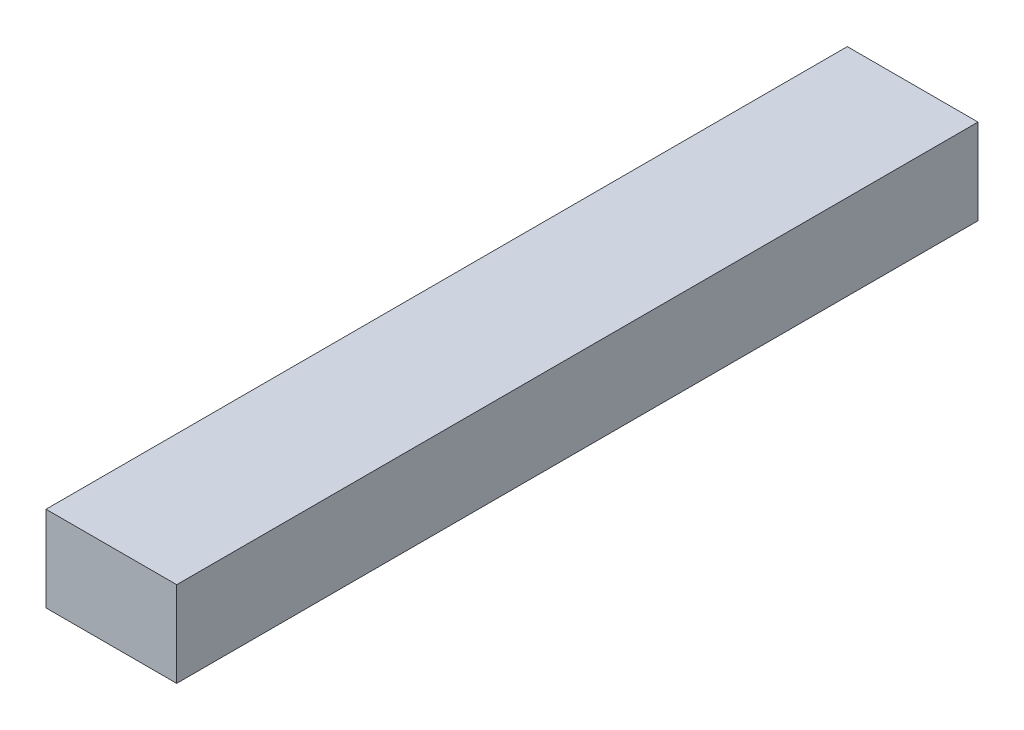
from build123d import *

# Parameters (mm, degrees)
ESQUISSE1_W        = 33.6
ESQUISSE1_H        = 21.98
BOSS_EXTRU_1_DEPTH = 206


with BuildPart() as part:
    # Esquisse1 → Boss.-Extru.1 (new body)
    with BuildSketch(Plane.XY):
        with Locations((16.8, 10.99)):
            Rectangle(ESQUISSE1_W, ESQUISSE1_H)
    extrude(amount=BOSS_EXTRU_1_DEPTH)


solid = part.part
